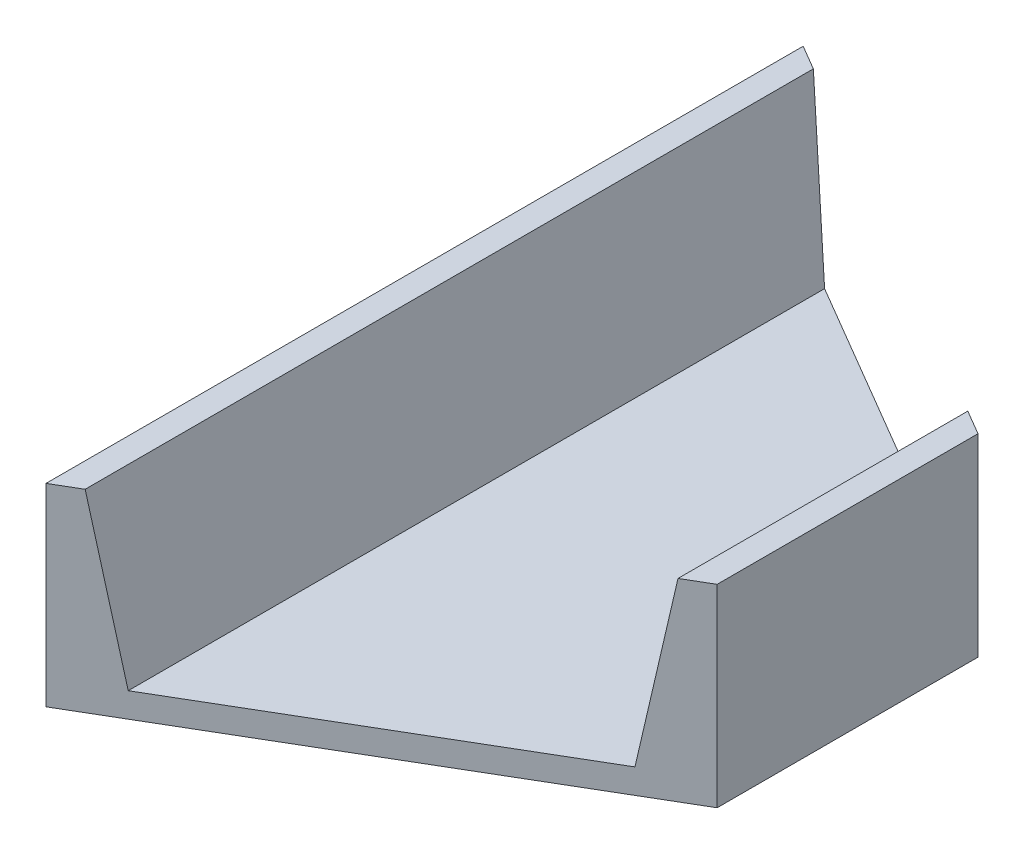
from build123d import *

# Parameters (mm, degrees)
BOSS_EXTRUDE1_DEPTH     = 136.398
CUT_EXTRUDE1_DEPTH      = 18.43075
CUT_EXTRUDE1_DEPTH_BACK = 18.43075


with BuildPart() as part:
    # Sketch1 → Boss-Extrude1 (new body)
    with BuildSketch(Plane.XY):
        Polygon((-28.7655, -12.98575), (28.7655, -12.98575), (33.655, 17.43075), (38.1, 17.43075), (38.1, -17.43075), (-38.1, -17.43075), (-38.1, 17.43075), (-33.655, 17.43075), align=None)
    extrude(amount=BOSS_EXTRUDE1_DEPTH)

    # Sketch2 → Cut-Extrude1 (cut, two sides)
    with BuildSketch(Plane(origin=(0, 0, 0), x_dir=(1, 0, 0), z_dir=(0, 1, 0))) as cut_extrude1_sk:
        Polygon((-38.1, 0), (38.1, -44.704), (38.1, 0), align=None)
        Polygon((-38.1, -136.398), (38.1, -91.694), (38.1, -136.398), align=None)
    extrude(amount=CUT_EXTRUDE1_DEPTH, mode=Mode.SUBTRACT)
    extrude(cut_extrude1_sk.sketch, amount=-CUT_EXTRUDE1_DEPTH_BACK, mode=Mode.SUBTRACT)


solid = part.part
